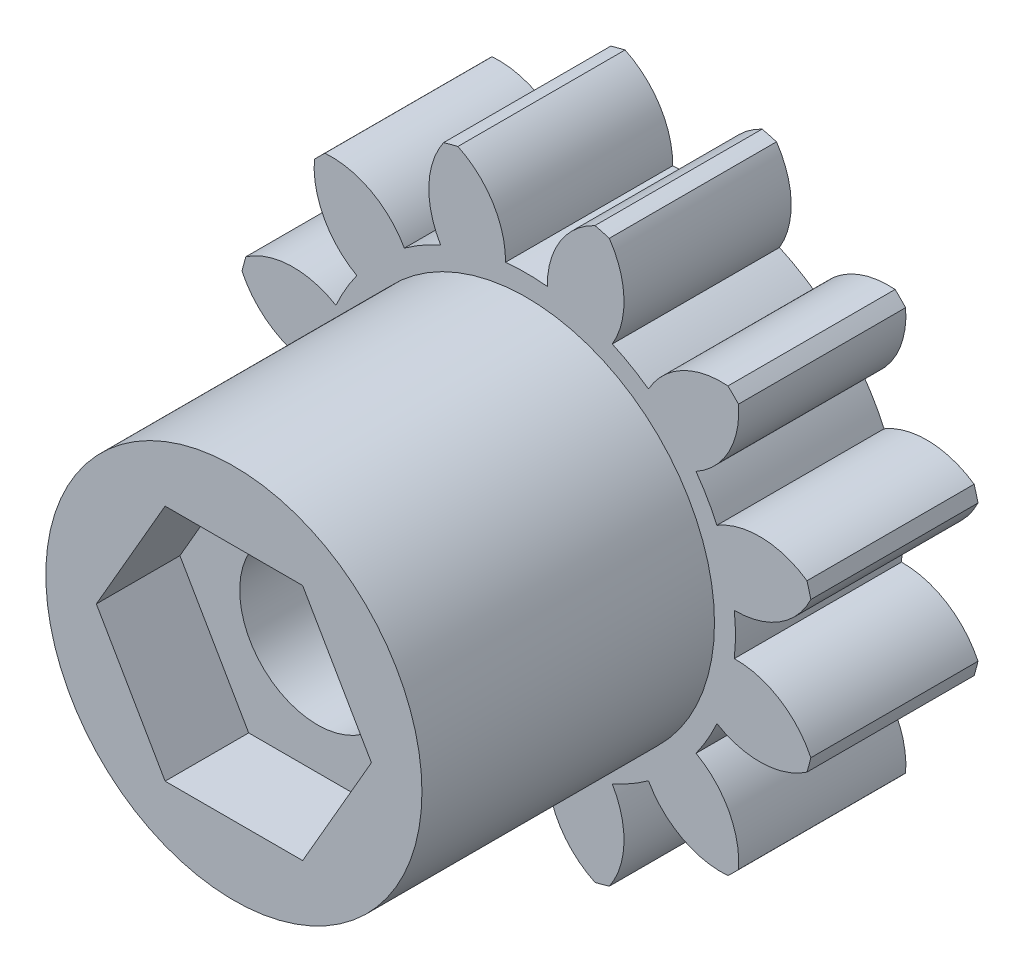
from build123d import *

# Parameters (mm, degrees)
SKETCH1_R           = 7
SKETCH1_R_2         = 1
BOSS_EXTRUDE1_DEPTH = 4
CUT_EXTRUDE2_DEPTH  = 11.677078252
CIRPATTERN2_COUNT   = 12
SKETCH11_R          = 4.5
BOSS_EXTRUDE2_DEPTH = 11
CUT_EXTRUDE3_START  = 11
CUT_EXTRUDE3_DEPTH  = 2
CUT_EXTRUDE4_DEPTH  = 15.615923436


with BuildPart() as part:
    # Sketch1 → Boss-Extrude1 (new body)
    with BuildSketch(Plane.XY):
        Circle(SKETCH1_R)
        Circle(SKETCH1_R_2, mode=Mode.SUBTRACT)
    extrude(amount=BOSS_EXTRUDE1_DEPTH)

    # Sketch4 → Cut-Extrude2 (cut, through all)
    with BuildSketch(Plane.XY):
        with BuildLine():
            ThreePointArc((-0.50015724, 4.97492138), (0, 5), (0.50015724, 4.97492138))
            ThreePointArc((0.50015724, 4.97492138), (1.158572372, 6.483432479), (2.72550834, 6.98724583))
            ThreePointArc((2.72550834, 6.98724583), (0, 7.5), (-2.72550834, 6.98724583))
            ThreePointArc((-2.72550834, 6.98724583), (-1.167899531, 6.491813775), (-0.5, 5))
            ThreePointArc((-0.5, 5), (-0.500039311, 4.987460443), (-0.50015724, 4.97492138))
        make_face()
    cut_extrude2 = extrude(amount=CUT_EXTRUDE2_DEPTH, mode=Mode.SUBTRACT)

    # CirPattern2: Cut-Extrude2 ×12 about axis
    cirpattern2_axis = Axis((0, 0, 4), (0, 0, -1))
    for i in range(1, CIRPATTERN2_COUNT):
        add(cut_extrude2.rotate(cirpattern2_axis, i * 360 / CIRPATTERN2_COUNT), mode=Mode.SUBTRACT)

    # Sketch11 → Boss-Extrude2 (add)
    with BuildSketch(Plane.XY):
        Circle(SKETCH11_R)
    extrude(amount=BOSS_EXTRUDE2_DEPTH)

    # Sketch12 → Cut-Extrude3 (cut)
    with BuildSketch(Plane.XY.offset(CUT_EXTRUDE3_START)):
        Polygon((3.290896534, 0), (1.645448267, 2.85), (-1.645448267, 2.85), (-3.290896534, 0), (-1.645448267, -2.85), (1.645448267, -2.85), align=None)
    extrude(amount=-CUT_EXTRUDE3_DEPTH, mode=Mode.SUBTRACT)

    # Sketch13 → Cut-Extrude4 (cut, through all)
    with BuildSketch(Plane.XY):
        with BuildLine():
            ThreePointArc((-1.6, 0.95), (0, -1.860779407), (1.6, 0.95))
            Line((1.6, 0.95), (-1.6, 0.95))
        make_face()
    extrude(amount=CUT_EXTRUDE4_DEPTH, mode=Mode.SUBTRACT)


solid = part.part
